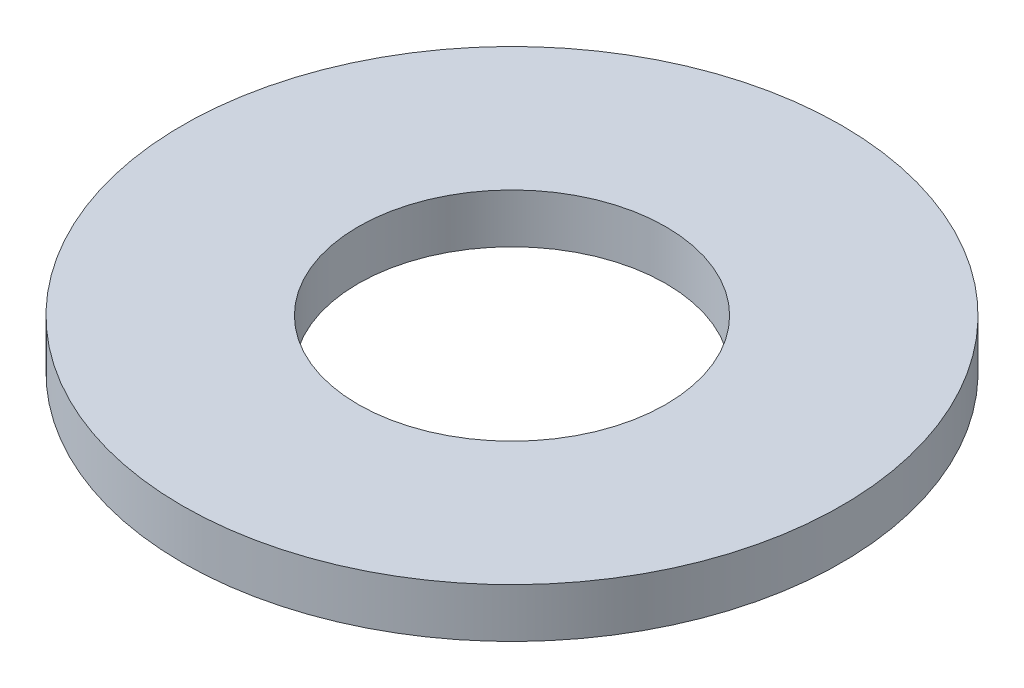
from build123d import *

# Parameters (mm, degrees)
SKETCH2_R           = 3.48
SKETCH2_R_2         = 1.625
BOSS_EXTRUDE1_DEPTH = 0.52


with BuildPart() as part:
    # Sketch2 → Boss-Extrude1 (new body)
    with BuildSketch(Plane(origin=(0, 0, 0), x_dir=(1, 0, 0), z_dir=(0, 1, 0))):
        Circle(SKETCH2_R)
        Circle(SKETCH2_R_2, mode=Mode.SUBTRACT)
    extrude(amount=BOSS_EXTRUDE1_DEPTH)


solid = part.part
